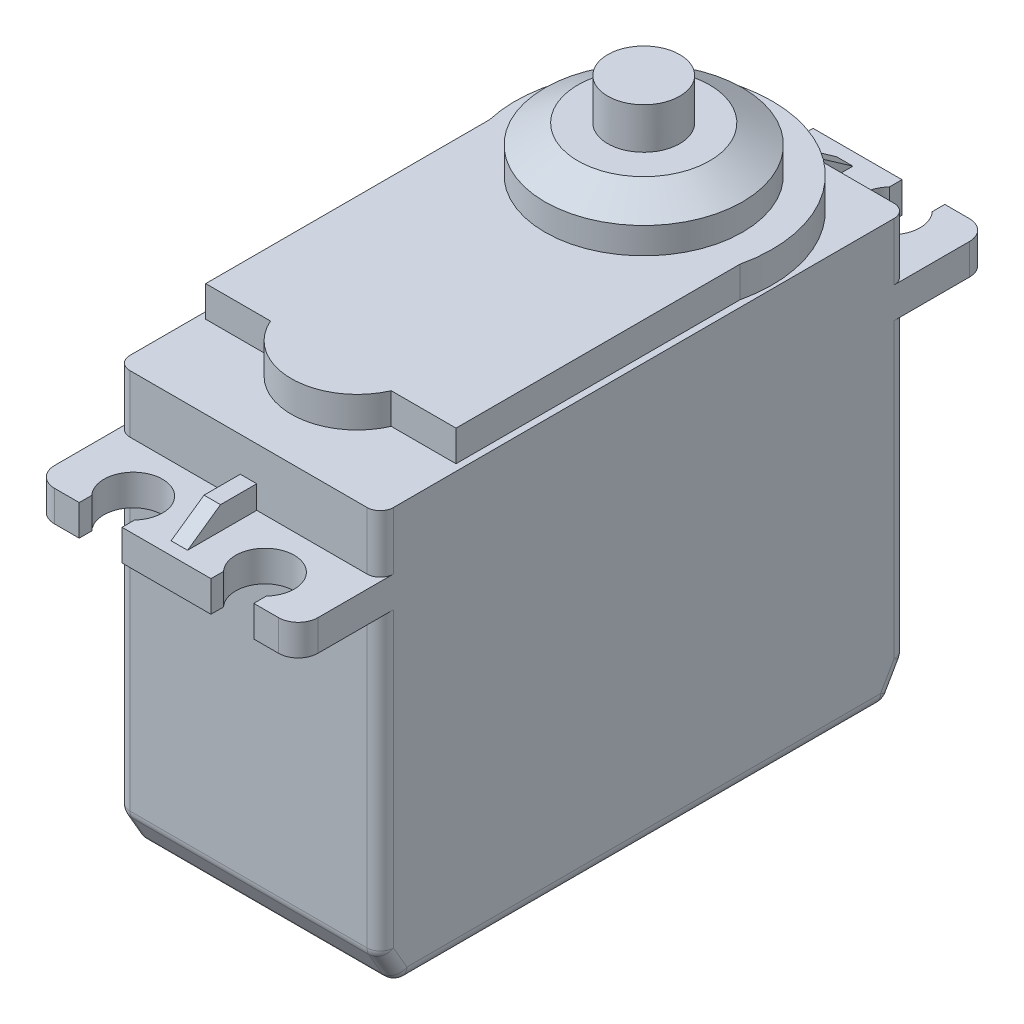
from build123d import *

# Parameters (mm, degrees)
SKETCH1_W             = 20.32
SKETCH1_H             = 40.64
EXTRUDE1_DEPTH        = 25.4
SKETCH2_W             = 20.32
SKETCH2_H             = 40.64
EXTRUDE2_DEPTH        = 2.38125
SKETCH3_W             = 20.32
SKETCH3_H             = 40.64
EXTRUDE3_DEPTH        = 4.445
EXTRUDE4_DEPTH        = 2.38125
SKETCH5_R             = 7.62
EXTRUDE5_DEPTH        = 3.4925
CHAMFER1_SIZE         = 2.54
CHAMFER1_SIZE2        = 1.466469684
EXTRUDE6_DEPTH        = 0.635
SKETCH8_R             = 2.778125
EXTRUDE7_DEPTH        = 3.175
CHAMFER2_SIZE         = 2.54
CHAMFER2_SIZE2        = 1.466469684
CHAMFER2_PART_2_SIZE  = 2.54
CHAMFER2_PART_2_SIZE2 = 1.466469684
FILLET1_R             = 1.016
FILLET2_R             = 1.524
SKETCH9_W             = 6.35
SKETCH9_H             = 2.54
EXTRUDE8_DEPTH        = 2.38125
SKETCH10_W            = 5.08
SKETCH10_H            = 1.27
CUT_EXTRUDE1_DEPTH    = 2.38125


with BuildPart() as part:
    # Sketch1 → Extrude1 (new body)
    with BuildSketch(Plane(origin=(0, 0, 0), x_dir=(1, 0, 0), z_dir=(0, 1, 0))):
        with Locations((0, -10.16)):
            Rectangle(SKETCH1_W, SKETCH1_H)
    extrude(amount=EXTRUDE1_DEPTH)

    # Sketch2 → Extrude2 (add)
    with BuildSketch(Plane(origin=(0, 25.4, 0), x_dir=(-1, 0, 0), z_dir=(0, 1, 0))):
        with Locations((0, 10.16)):
            Rectangle(SKETCH2_W, SKETCH2_H)
        with BuildLine():
            ThreePointArc((6.731, -15.51418631), (5.08, -11.7094), (3.429, -15.51418631))
            Line((3.429, -15.51418631), (3.429, -16.4846))
            Line((3.429, -16.4846), (-3.429, -16.4846))
            Line((-3.429, -16.4846), (-3.429, -15.51418631))
            ThreePointArc((-3.429, -15.51418631), (-5.08, -11.7094), (-6.731, -15.51418631))
            Line((-6.731, -15.51418631), (-6.731, -16.4846))
            Line((-6.731, -16.4846), (-10.16, -16.4846))
            Line((-10.16, -16.4846), (-10.16, -10.16))
            Line((-10.16, -10.16), (10.16, -10.16))
            Line((10.16, -10.16), (10.16, -16.4846))
            Line((10.16, -16.4846), (6.731, -16.4846))
            Line((6.731, -16.4846), (6.731, -15.51418631))
        make_face()
        with BuildLine():
            ThreePointArc((-6.731, 35.83418631), (-5.08, 32.0294), (-3.429, 35.83418631))
            Line((-3.429, 35.83418631), (-3.429, 36.8046))
            Line((-3.429, 36.8046), (3.429, 36.8046))
            Line((3.429, 36.8046), (3.429, 35.83418631))
            ThreePointArc((3.429, 35.83418631), (5.08, 32.0294), (6.731, 35.83418631))
            Line((6.731, 35.83418631), (6.731, 36.8046))
            Line((6.731, 36.8046), (10.16, 36.8046))
            Line((10.16, 36.8046), (10.16, 30.48))
            Line((10.16, 30.48), (-10.16, 30.48))
            Line((-10.16, 30.48), (-10.16, 36.8046))
            Line((-10.16, 36.8046), (-6.731, 36.8046))
            Line((-6.731, 36.8046), (-6.731, 35.83418631))
        make_face()
    extrude(amount=EXTRUDE2_DEPTH)

    # Sketch3 → Extrude3 (add)
    with BuildSketch(Plane(origin=(0, 27.78125, 0), x_dir=(-1, 0, 0), z_dir=(0, 1, 0))):
        with Locations((0, 10.16)):
            Rectangle(SKETCH3_W, SKETCH3_H)
    extrude(amount=EXTRUDE3_DEPTH)

    # Sketch4 → Extrude4 (add)
    with BuildSketch(Plane(origin=(0, 32.22625, 0), x_dir=(-1, 0, 0), z_dir=(0, 1, 0))):
        with BuildLine():
            Line((9.652, 2.228840954), (9.652, 24.13))
            Line((9.652, 24.13), (4.655896906, 24.13))
            ThreePointArc((4.655896906, 24.13), (0, 27.178), (-4.655896906, 24.13))
            Line((-4.655896906, 24.13), (-9.652, 24.13))
            Line((-9.652, 24.13), (-9.652, 2.228840954))
            ThreePointArc((-9.652, 2.228840954), (0, -9.906), (9.652, 2.228840954))
        make_face()
    extrude(amount=EXTRUDE4_DEPTH)

    # Sketch5 → Extrude5 (add)
    with BuildSketch(Plane(origin=(0, 34.6075, 0), x_dir=(-1, 0, 0), z_dir=(0, 1, 0))):
        Circle(SKETCH5_R)
    extrude(amount=EXTRUDE5_DEPTH)

    # Chamfer1
    chamfer1_edges = [part.edges().sort_by_distance(p)[0] for p in [
        (7.62, 38.1, 0),
    ]]
    chamfer1_side = [part.faces().sort_by_distance(p)[0] for p in [
        (0, 38.1, 0),
    ]]
    chamfer(chamfer1_edges, length=CHAMFER1_SIZE, length2=CHAMFER1_SIZE2, reference=chamfer1_side[0])

    # Sketch7 → Extrude6 (add, symmetric)
    with BuildSketch(Plane(origin=(0, 0, 0), x_dir=(0, 0, -1), z_dir=(1, 0, 0))):
        Polygon((15.494, 27.78125), (12.954, 29.55925), (10.16, 29.55925), (10.16, 27.78125), align=None)
    extrude6 = extrude(amount=EXTRUDE6_DEPTH, both=True)

    # Mirror1: Extrude6 across plane
    add(extrude6.mirror(Plane(origin=(0, 0, 10.16), x_dir=(1, 0, 0), z_dir=(0, 0, -1))))

    # Sketch8 → Extrude7 (add)
    with BuildSketch(Plane(origin=(0, 38.1, 0), x_dir=(-1, 0, 0), z_dir=(0, 1, 0))):
        Circle(SKETCH8_R)
    extrude(amount=EXTRUDE7_DEPTH)

    # Chamfer2
    chamfer2_edges = [part.edges().sort_by_distance(p)[0] for p in [
        (0, 0, -10.16),
    ]]
    chamfer2_side = [part.faces().sort_by_distance(p)[0] for p in [
        (0, 12.7, -10.16),
    ]]
    chamfer(chamfer2_edges, length=CHAMFER2_SIZE, length2=CHAMFER2_SIZE2, reference=chamfer2_side[0])

    # Chamfer2 part 2
    chamfer2_part_2_edges = [part.edges().sort_by_distance(p)[0] for p in [
        (0, 0, 30.48),
    ]]
    chamfer2_part_2_side = [part.faces().sort_by_distance(p)[0] for p in [
        (0, 12.7, 30.48),
    ]]
    chamfer(chamfer2_part_2_edges, length=CHAMFER2_PART_2_SIZE, length2=CHAMFER2_PART_2_SIZE2, reference=chamfer2_part_2_side[0])

    # Fillet1
    fillet1_edges = [part.edges().sort_by_distance(p)[0] for p in [
        (-10.16, 30.00375, -10.16),
        (10.16, 30.00375, -10.16),
        (10.16, 30.00375, 30.48),
        (10.16, 0, 10.16),
        (10.16, 1.27, -9.426765158),
        (10.16, 13.97, -10.16),
        (0, 0, -8.693530316),
        (0, 2.54, -10.16),
        (-10.16, 13.97, -10.16),
        (-10.16, 1.27, -9.426765158),
        (10.16, 13.97, 30.48),
        (10.16, 1.27, 29.746765158),
        (0, 2.54, 30.48),
        (-10.16, 0, 10.16),
        (0, 0, 29.013530316),
        (-10.16, 1.27, 29.746765158),
        (-10.16, 13.97, 30.48),
        (-10.16, 30.00375, 30.48),
    ]]
    fillet(fillet1_edges, radius=FILLET1_R)

    # Fillet2
    fillet2_edges = [part.edges().sort_by_distance(p)[0] for p in [
        (-10.16, 26.590625, 36.8046),
        (10.16, 26.590625, 36.8046),
        (-10.16, 26.590625, -16.4846),
        (10.16, 26.590625, -16.4846),
    ]]
    fillet(fillet2_edges, radius=FILLET2_R)

    # Sketch9 → Extrude8 (add)
    with BuildSketch(Plane(origin=(0, 0, -10.16), x_dir=(-1, 0, 0), z_dir=(0, 0, -1))):
        with Locations((0, 4.318)):
            Rectangle(SKETCH9_W, SKETCH9_H)
    extrude(amount=EXTRUDE8_DEPTH)

    # Sketch10 → Cut-Extrude1 (cut)
    with BuildSketch(Plane(origin=(0, 0, -12.54125), x_dir=(-1, 0, 0), z_dir=(0, 0, -1))):
        with Locations((0, 4.318)):
            Rectangle(SKETCH10_W, SKETCH10_H)
    extrude(amount=-CUT_EXTRUDE1_DEPTH, mode=Mode.SUBTRACT)


solid = part.part
